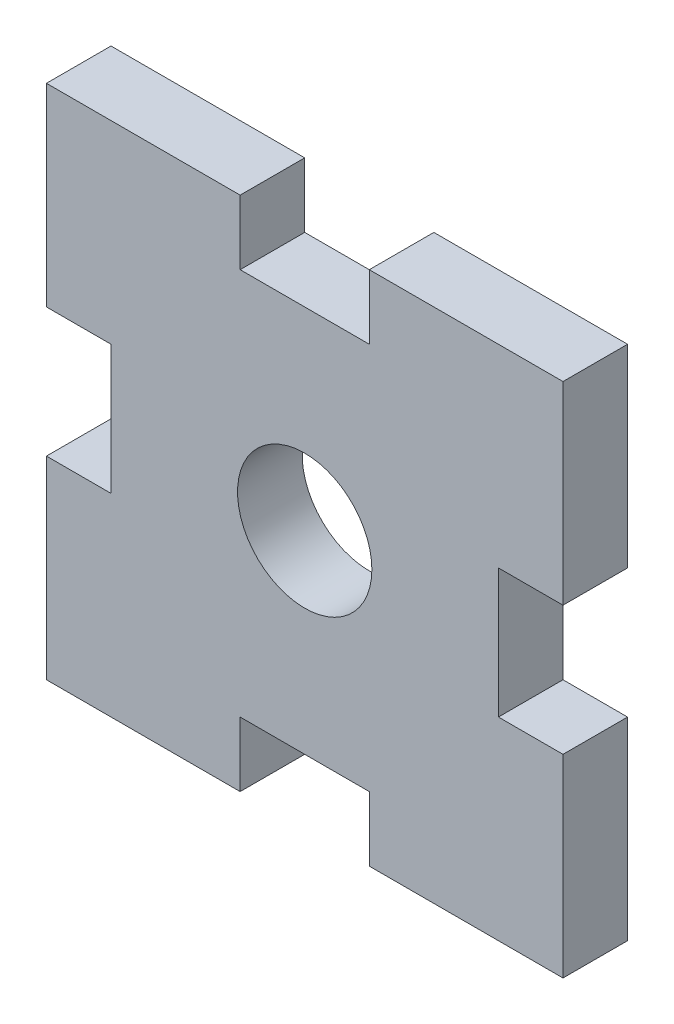
from build123d import *

# Parameters (mm, degrees)
SKETCH1_R      = 3.302
EXTRUDE1_DEPTH = 3.175


with BuildPart() as part:
    # Sketch1 → Extrude1 (new body)
    with BuildSketch(Plane.XY):
        Polygon((-12.7, 12.7), (-3.175, 12.7), (-3.175, 9.525), (3.175, 9.525), (3.175, 12.7), (12.7, 12.7), (12.7, 3.175), (9.525, 3.175), (9.525, -3.175), (12.7, -3.175), (12.7, -12.7), (3.175, -12.7), (3.175, -9.525), (-3.175, -9.525), (-3.175, -12.7), (-12.7, -12.7), (-12.7, -3.175), (-9.525, -3.175), (-9.525, 3.175), (-12.7, 3.175), align=None)
        Circle(SKETCH1_R, mode=Mode.SUBTRACT)
    extrude(amount=EXTRUDE1_DEPTH)


solid = part.part
